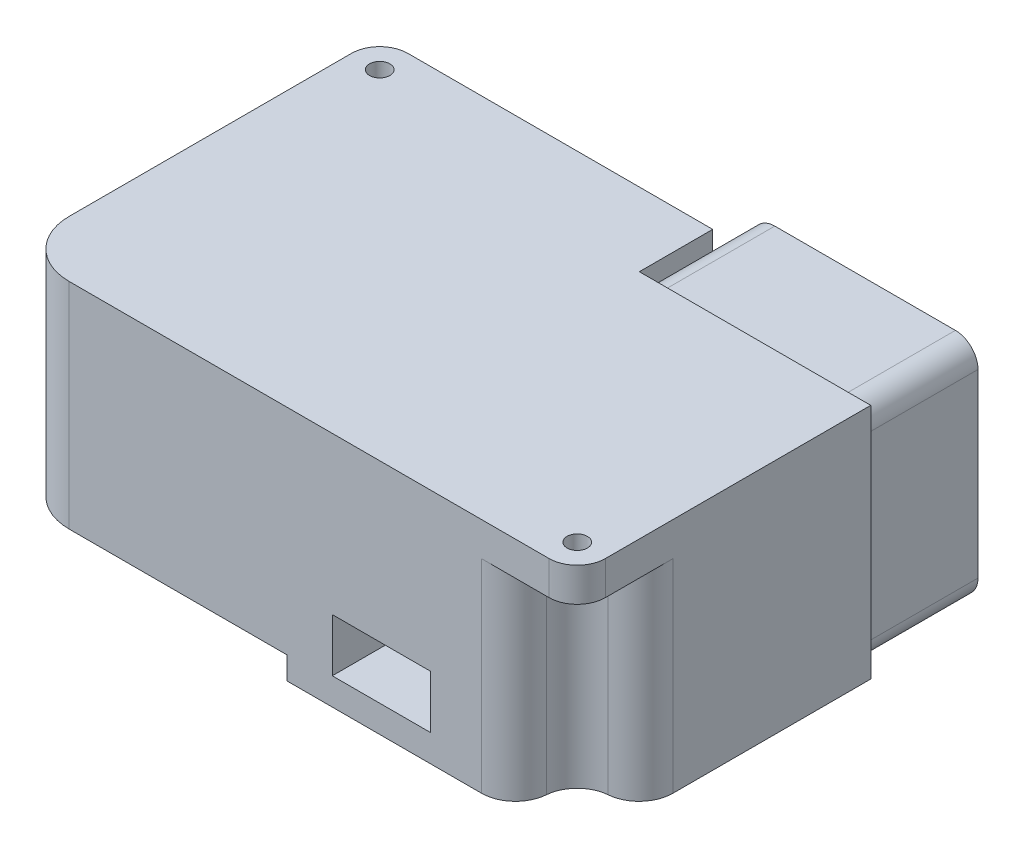
from build123d import *

# Parameters (mm, degrees)
SKETCH_1_R          = 0.9
EXTRUDE_1_DEPTH     = 3
EXTRUDE_2_DEPTH     = 19
EXTRUDE_3_DEPTH     = 2
SKETCH_5_W          = 8.7
SKETCH_5_H          = 4.7
CUT_EXTRUDE_1_DEPTH = 6.3
EXTRUDE_4_DEPTH     = 10


with BuildPart() as part:
    # 草图1 → 凸台-拉伸1 (new body)
    with BuildSketch(Plane(origin=(0, 0, 0), x_dir=(1, 0, 0), z_dir=(0, 1, 0))):
        with BuildLine():
            Line((4.5, 16.25), (4.5, 9.75))
            Line((4.5, 9.75), (25, 9.75))
            Line((25, 9.75), (25, -13.75))
            ThreePointArc((25, -13.75), (24.267766953, -15.517766953), (22.5, -16.25))
            Line((22.5, -16.25), (-20, -16.25))
            ThreePointArc((-20, -16.25), (-23.535533906, -14.785533906), (-25, -11.25))
            Line((-25, -11.25), (-25, 13.75))
            ThreePointArc((-25, 13.75), (-24.267766953, 15.517766953), (-22.5, 16.25))
            Line((-22.5, 16.25), (4.5, 16.25))
        make_face()
        with Locations((-22.5, 13.75)):
            Circle(SKETCH_1_R, mode=Mode.SUBTRACT)
        with Locations((22.5, -13.75)):
            Circle(SKETCH_1_R, mode=Mode.SUBTRACT)
    extrude(amount=EXTRUDE_1_DEPTH)

    # 草图2 → 凸台-拉伸2 (add)
    with BuildSketch(Plane(origin=(0, 3, 0), x_dir=(1, 0, 0), z_dir=(0, 1, 0))):
        with BuildLine():
            Line((4.5, 16.25), (-16.520869628, 16.25))
            ThreePointArc((-16.520869628, 16.25), (-18.55187923, 15.457940217), (-19.510434814, 13.5))
            ThreePointArc((-19.510434814, 13.5), (-20.378679656, 11.628679656), (-22.25, 10.760434814))
            ThreePointArc((-22.25, 10.760434814), (-24.207940217, 9.80187923), (-25, 7.770869628))
            Line((-25, 7.770869628), (-25, -11.25))
            ThreePointArc((-25, -11.25), (-23.535533906, -14.785533906), (-20, -16.25))
            Line((-20, -16.25), (16.520869628, -16.25))
            ThreePointArc((16.520869628, -16.25), (18.55187923, -15.457940217), (19.510434814, -13.5))
            ThreePointArc((19.510434814, -13.5), (20.378679656, -11.628679656), (22.25, -10.760434814))
            ThreePointArc((22.25, -10.760434814), (24.207940217, -9.80187923), (25, -7.770869628))
            Line((25, -7.770869628), (25, 9.75))
            Line((25, 9.75), (4.5, 9.75))
            Line((4.5, 9.75), (4.5, 16.25))
        make_face()
    extrude(amount=-EXTRUDE_2_DEPTH)

    # 草图4 → 凸台-拉伸3 (add)
    with BuildSketch(Plane.XZ.offset(16)):
        with BuildLine():
            Line((-0.7, -16.25), (-0.7, 16.25))
            Line((-0.7, 16.25), (16.520869628, 16.25))
            ThreePointArc((16.520869628, 16.25), (18.55187923, 15.457940217), (19.510434814, 13.5))
            ThreePointArc((19.510434814, 13.5), (20.378679656, 11.628679656), (22.25, 10.760434814))
            ThreePointArc((22.25, 10.760434814), (24.207940217, 9.80187923), (25, 7.770869628))
            Line((25, 7.770869628), (25, -9.75))
            Line((25, -9.75), (4.5, -9.75))
            Line((4.5, -9.75), (4.5, -16.25))
            Line((4.5, -16.25), (-0.7, -16.25))
        make_face()
    extrude(amount=EXTRUDE_3_DEPTH)

    # 草图5 → 切除-拉伸1 (cut)
    with BuildSketch(Plane.XY.offset(16.25)):
        with Locations((7.65, -13.25)):
            Rectangle(SKETCH_5_W, SKETCH_5_H)
    extrude(amount=-CUT_EXTRUDE_1_DEPTH, mode=Mode.SUBTRACT)

    # 草图6 → 凸台-拉伸4 (add)
    with BuildSketch(Plane(origin=(0, 0, -9.75), x_dir=(-1, 0, 0), z_dir=(0, 0, -1))):
        with BuildLine():
            Line((-6.5, 2.5), (-22.5, 2.5))
            ThreePointArc((-22.5, 2.5), (-23.914213562, 1.914213562), (-24.5, 0.5))
            Line((-24.5, 0.5), (-24.5, -15.5))
            ThreePointArc((-24.5, -15.5), (-23.914213562, -16.914213562), (-22.5, -17.5))
            Line((-22.5, -17.5), (-6.5, -17.5))
            ThreePointArc((-6.5, -17.5), (-5.085786438, -16.914213562), (-4.5, -15.5))
            Line((-4.5, -15.5), (-4.5, 0.5))
            ThreePointArc((-4.5, 0.5), (-5.085786438, 1.914213562), (-6.5, 2.5))
        make_face()
        with BuildLine():
            Line((-14.5, -13.75), (-12.034104017, -16.467126463))
            ThreePointArc((-12.034104017, -16.467126463), (-5.896292843, -11.030753907), (-6.445963745, -2.85))
            Line((-6.445963745, -2.85), (-8.548360144, -9.408004985))
            ThreePointArc((-8.548360144, -9.408004985), (-10.816423691, -12.549135132), (-14.5, -13.75))
        make_face(mode=Mode.SUBTRACT)
        with BuildLine():
            Line((-14.5, -16.8), (-19.128200716, -11.700268817))
            ThreePointArc((-19.128200716, -11.700268817), (-20.714467446, -8.165503094), (-19.912658774, -4.375))
            Line((-19.912658774, -4.375), (-23.498707307, -5.151965333))
            ThreePointArc((-23.498707307, -5.151965333), (-21.859576156, -13.185652012), (-14.5, -16.8))
        make_face(mode=Mode.SUBTRACT)
        with BuildLine():
            Line((-22.554036255, -2.85), (-15.823439141, -1.391726198))
            ThreePointArc((-15.823439141, -1.391726198), (-11.969108863, -1.785361774), (-9.087341226, -4.375))
            Line((-9.087341226, -4.375), (-7.967188676, -0.880908204))
            ThreePointArc((-7.967188676, -0.880908204), (-15.744131001, 1.716405918), (-22.554036255, -2.85))
        make_face(mode=Mode.SUBTRACT)
    extrude(amount=EXTRUDE_4_DEPTH)


solid = part.part
